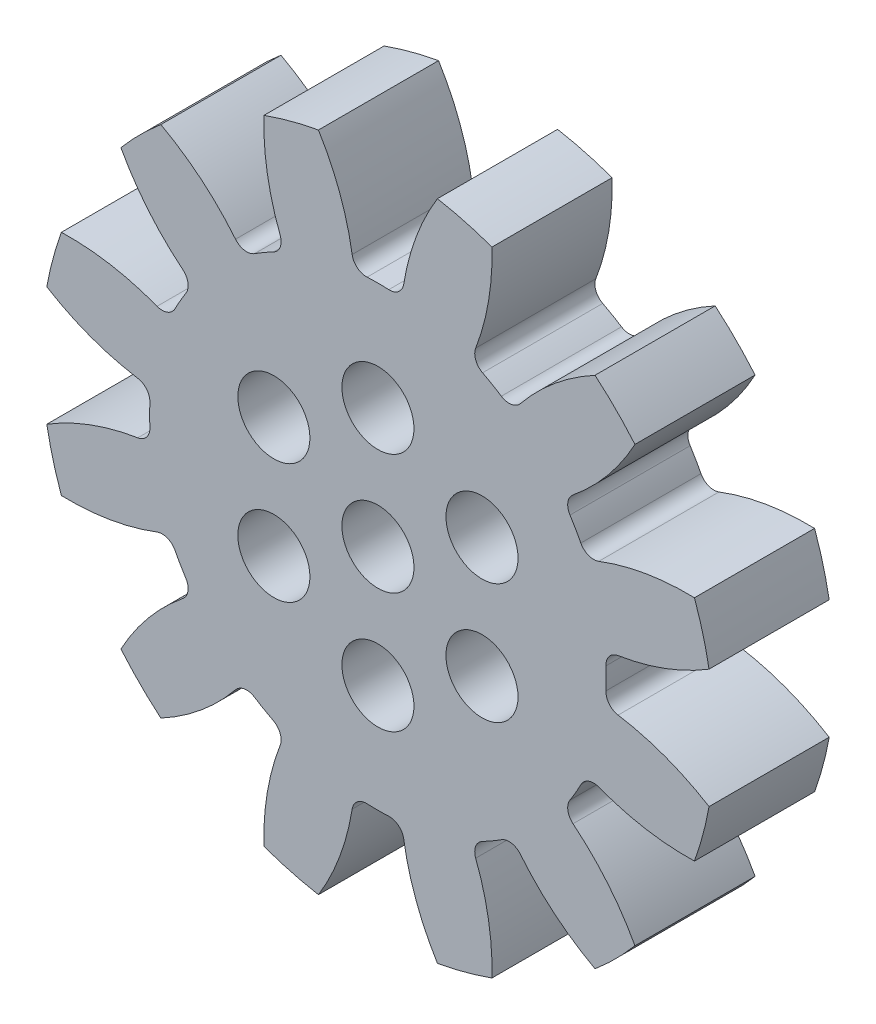
from build123d import *

# Parameters (mm, degrees)
SKETCH1_R                = 14
BOSS_EXTRUDE1_DEPTH      = 2.5
CUT_EXTRUDE1_DEPTH       = 3.5
FILLET1_R                = 0.6
FILLET2_R                = 0.6
CIRPATTERN2_COUNT        = 12
FILLET1_OF_CIRPATTERN2_R = 0.6
FILLET2_OF_CIRPATTERN2_R = 0.6
SKETCH4_R                = 1.5
CUT_EXTRUDE2_DEPTH       = 1.0000001
CUT_EXTRUDE2_DEPTH_BACK  = 6.0000001


with BuildPart() as part:
    # Sketch1 → Boss-Extrude1 (new body, symmetric)
    with BuildSketch(Plane.XY):
        Circle(SKETCH1_R)
    extrude(amount=BOSS_EXTRUDE1_DEPTH, both=True)

    # Sketch2 → Cut-Extrude1 (cut, symmetric)
    with BuildSketch(Plane.XY):
        with BuildLine():
            ThreePointArc((-3.314591405, 14.951229823), (-1.751535203, 12.36983933), (-0.999747632, 9.447248524))
            ThreePointArc((-0.999747632, 9.447248524), (0, 9.5), (0.999747632, 9.447248524))
            ThreePointArc((0.999747632, 9.447248524), (1.751535203, 12.36983933), (3.314591405, 14.951229823))
            ThreePointArc((3.314591405, 14.951229823), (0, 15.314234862), (-3.314591405, 14.951229823))
        make_face()
    cut_extrude1 = extrude(amount=CUT_EXTRUDE1_DEPTH, both=True, mode=Mode.SUBTRACT)

    # Fillet1
    fillet1_edges = [part.edges().sort_by_distance(p)[0] for p in [
        (-0.999747632, 9.447248524, 0),
    ]]
    fillet(fillet1_edges, radius=FILLET1_R)

    # Fillet2
    fillet2_edges = [part.edges().sort_by_distance(p)[0] for p in [
        (0.999747632, 9.447248524, 0),
    ]]
    fillet(fillet2_edges, radius=FILLET2_R)

    # CirPattern2: Cut-Extrude1 ×12 about axis
    cirpattern2_axis = Axis((0, 0, 0), (0, 0, 1))
    for i in range(1, CIRPATTERN2_COUNT):
        add(cut_extrude1.rotate(cirpattern2_axis, i * 360 / CIRPATTERN2_COUNT), mode=Mode.SUBTRACT)

    # Fillet1 of CirPattern2
    fillet1_of_cirpattern2_edges = [part.edges().sort_by_distance(p)[0] for p in [
        (-5.589431109, 7.681683401, 0),
        (-8.681431034, 3.857817415, 0),
        (-9.447248524, -0.999747632, 0),
        (-7.681683401, -5.589431109, 0),
        (-3.857817415, -8.681431034, 0),
        (0.999747632, -9.447248524, 0),
        (5.589431109, -7.681683401, 0),
        (8.681431034, -3.857817415, 0),
        (9.447248524, 0.999747632, 0),
        (7.681683401, 5.589431109, 0),
        (3.857817415, 8.681431034, 0),
    ]]
    fillet(fillet1_of_cirpattern2_edges, radius=FILLET1_OF_CIRPATTERN2_R)

    # Fillet2 of CirPattern2
    fillet2_of_cirpattern2_edges = [part.edges().sort_by_distance(p)[0] for p in [
        (-3.857817415, 8.681431034, 0),
        (-7.681683401, 5.589431109, 0),
        (-9.447248524, 0.999747632, 0),
        (-8.681431034, -3.857817415, 0),
        (-5.589431109, -7.681683401, 0),
        (-0.999747632, -9.447248524, 0),
        (3.857817415, -8.681431034, 0),
        (7.681683401, -5.589431109, 0),
        (9.447248524, -0.999747632, 0),
        (8.681431034, 3.857817415, 0),
        (5.589431109, 7.681683401, 0),
    ]]
    fillet(fillet2_of_cirpattern2_edges, radius=FILLET2_OF_CIRPATTERN2_R)

    # Sketch4 → Cut-Extrude2 (cut, two sides)
    with BuildSketch(Plane.XY.offset(2.5)) as cut_extrude2_sk:
        Circle(SKETCH4_R)
        with Locations((0, 5)):
            Circle(SKETCH4_R)
        with Locations((4.330127019, 2.5)):
            Circle(SKETCH4_R)
        with Locations((4.330127019, -2.5)):
            Circle(SKETCH4_R)
        with Locations((0, -5)):
            Circle(SKETCH4_R)
        with Locations((-4.330127019, -2.5)):
            Circle(SKETCH4_R)
        with Locations((-4.330127019, 2.5)):
            Circle(SKETCH4_R)
    extrude(amount=CUT_EXTRUDE2_DEPTH, mode=Mode.SUBTRACT)
    extrude(cut_extrude2_sk.sketch, amount=-CUT_EXTRUDE2_DEPTH_BACK, mode=Mode.SUBTRACT)


solid = part.part
